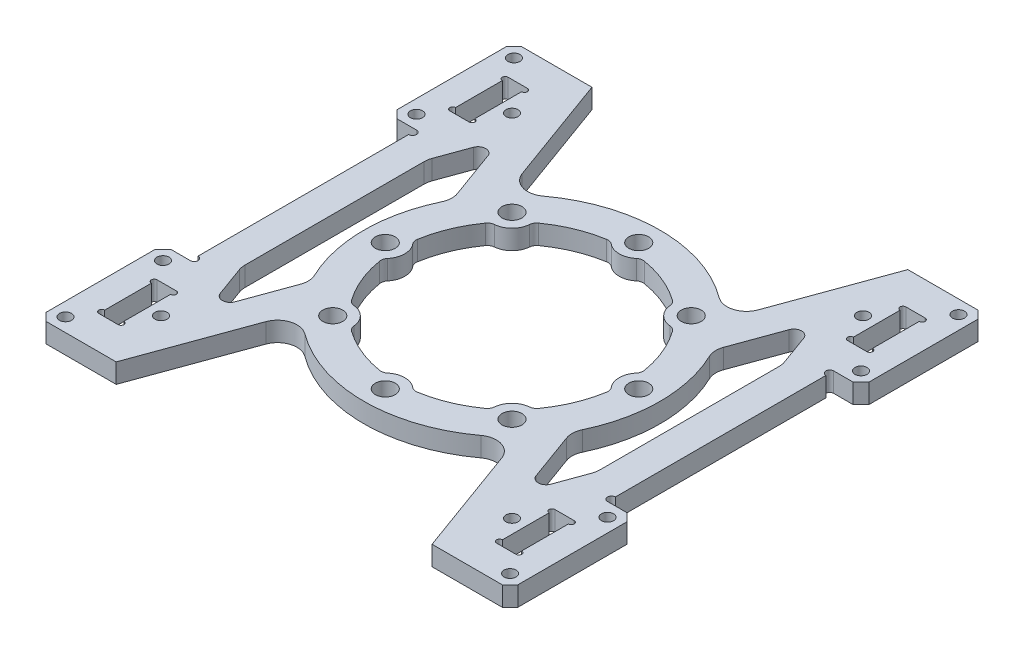
from build123d import *

# Parameters (mm, degrees)
SKETCH_1_W          = 121
SKETCH_1_H          = 122
SKETCH_1_R          = 2.55
SKETCH_1_R_2        = 1.55
SKETCH_1_W_2        = 4.95
SKETCH_1_H_2        = 14.95
EXTRUDE_1_DEPTH     = 2.5
FILLET_1_R          = 2
SKETCH_2_R          = 0.75
CUT_EXTRUDE_1_DEPTH = 6.0000001
SKETCH_3_W          = 7
SKETCH_3_H          = 58
CUT_EXTRUDE_2_DEPTH = 6.0000001
CUT_EXTRUDE_3_DEPTH = 6.0000001
FILLET_2_R          = 5
CUT_EXTRUDE_4_DEPTH = 6.0000001
FILLET_3_R          = 2
CHAMFER_1_SIZE      = 2
FILLET_4_R          = 5
SKETCH_6_R          = 1
CUT_EXTRUDE_5_DEPTH = 6.0000001


with BuildPart() as part:
    # 草图1 → 凸台-拉伸1 (new body, symmetric)
    with BuildSketch(Plane(origin=(0, 0, 0), x_dir=(1, 0, 0), z_dir=(0, 1, 0))):
        Rectangle(SKETCH_1_W, SKETCH_1_H)
        with Locations((0, 32.5)):
            Circle(SKETCH_1_R, mode=Mode.SUBTRACT)
        with Locations((22.980970389, 22.980970389)):
            Circle(SKETCH_1_R, mode=Mode.SUBTRACT)
        with Locations((32.5, 0)):
            Circle(SKETCH_1_R, mode=Mode.SUBTRACT)
        with Locations((22.980970389, -22.980970389)):
            Circle(SKETCH_1_R, mode=Mode.SUBTRACT)
        with Locations((0, -32.5)):
            Circle(SKETCH_1_R, mode=Mode.SUBTRACT)
        with Locations((-22.980970389, -22.980970389)):
            Circle(SKETCH_1_R, mode=Mode.SUBTRACT)
        with Locations((-32.5, 0)):
            Circle(SKETCH_1_R, mode=Mode.SUBTRACT)
        with Locations((-22.980970389, 22.980970389)):
            Circle(SKETCH_1_R, mode=Mode.SUBTRACT)
        with Locations((-57, 57.5)):
            Circle(SKETCH_1_R_2, mode=Mode.SUBTRACT)
        with Locations((-57, 32.5)):
            Circle(SKETCH_1_R_2, mode=Mode.SUBTRACT)
        with Locations((57, 32.5)):
            Circle(SKETCH_1_R_2, mode=Mode.SUBTRACT)
        with Locations((57, 57.5)):
            Circle(SKETCH_1_R_2, mode=Mode.SUBTRACT)
        with Locations((57, -32.5)):
            Circle(SKETCH_1_R_2, mode=Mode.SUBTRACT)
        with Locations((57, -57.5)):
            Circle(SKETCH_1_R_2, mode=Mode.SUBTRACT)
        with Locations((-57, -32.5)):
            Circle(SKETCH_1_R_2, mode=Mode.SUBTRACT)
        with Locations((-57, -57.5)):
            Circle(SKETCH_1_R_2, mode=Mode.SUBTRACT)
        with Locations((-45, 45)):
            Circle(SKETCH_1_R_2, mode=Mode.SUBTRACT)
        with Locations((45, 45)):
            Circle(SKETCH_1_R_2, mode=Mode.SUBTRACT)
        with Locations((45, -45)):
            Circle(SKETCH_1_R_2, mode=Mode.SUBTRACT)
        with Locations((-45, -45)):
            Circle(SKETCH_1_R_2, mode=Mode.SUBTRACT)
        with Locations((-51, 45)):
            Rectangle(SKETCH_1_W_2, SKETCH_1_H_2, mode=Mode.SUBTRACT)
        with Locations((-51, -45)):
            Rectangle(SKETCH_1_W_2, SKETCH_1_H_2, mode=Mode.SUBTRACT)
        with Locations((51, -45)):
            Rectangle(SKETCH_1_W_2, SKETCH_1_H_2, mode=Mode.SUBTRACT)
        with Locations((51, 45)):
            Rectangle(SKETCH_1_W_2, SKETCH_1_H_2, mode=Mode.SUBTRACT)
        with BuildLine():
            ThreePointArc((-23.374689978, 17.996496005), (-27.254446209, 11.289161255), (-29.253846154, 3.802957429))
            ThreePointArc((-29.253846154, 3.802957429), (-27.5, 0), (-29.253846154, -3.802957429))
            ThreePointArc((-29.253846154, -3.802957429), (-27.254446209, -11.289161255), (-23.374689978, -17.996496005))
            ThreePointArc((-23.374689978, -17.996496005), (-19.445436483, -19.445436483), (-17.996496005, -23.374689978))
            ThreePointArc((-17.996496005, -23.374689978), (-11.289161255, -27.254446209), (-3.802957429, -29.253846154))
            ThreePointArc((-3.802957429, -29.253846154), (0, -27.5), (3.802957429, -29.253846154))
            ThreePointArc((3.802957429, -29.253846154), (11.289161255, -27.254446209), (17.996496005, -23.374689978))
            ThreePointArc((17.996496005, -23.374689978), (19.445436483, -19.445436483), (23.374689978, -17.996496005))
            ThreePointArc((23.374689978, -17.996496005), (27.254446209, -11.289161255), (29.253846154, -3.802957429))
            ThreePointArc((29.253846154, -3.802957429), (27.5, 0), (29.253846154, 3.802957429))
            ThreePointArc((29.253846154, 3.802957429), (27.254446209, 11.289161255), (23.374689978, 17.996496005))
            ThreePointArc((23.374689978, 17.996496005), (19.445436483, 19.445436483), (17.996496005, 23.374689978))
            ThreePointArc((17.996496005, 23.374689978), (11.289161255, 27.254446209), (3.802957429, 29.253846154))
            ThreePointArc((3.802957429, 29.253846154), (0, 27.5), (-3.802957429, 29.253846154))
            ThreePointArc((-3.802957429, 29.253846154), (-11.289161255, 27.254446209), (-17.996496005, 23.374689978))
            ThreePointArc((-17.996496005, 23.374689978), (-19.445436483, 19.445436483), (-23.374689978, 17.996496005))
        make_face(mode=Mode.SUBTRACT)
    extrude(amount=EXTRUDE_1_DEPTH, both=True)

    # 圆角1
    fillet_1_edges = [part.edges().sort_by_distance(p)[0] for p in [
        (-17.996496005, 0, -23.374689978),
        (-23.374689978, 0, -17.996496005),
        (-29.253846154, 0, -3.802957429),
        (-29.253846154, 0, 3.802957429),
        (-23.374689978, 0, 17.996496005),
        (-17.996496005, 0, 23.374689978),
        (-3.802957429, 0, 29.253846154),
        (3.802957429, 0, 29.253846154),
        (17.996496005, 0, 23.374689978),
        (23.374689978, 0, 17.996496005),
        (29.253846154, 0, 3.802957429),
        (29.253846154, 0, -3.802957429),
        (23.374689978, 0, -17.996496005),
        (17.996496005, 0, -23.374689978),
        (3.802957429, 0, -29.253846154),
        (-3.802957429, 0, -29.253846154),
    ]]
    fillet(fillet_1_edges, radius=FILLET_1_R)

    # 草图2 → 切除-拉伸1 (cut, through all)
    with BuildSketch(Plane(origin=(0, 2.5, 0), x_dir=(1, 0, 0), z_dir=(0, 1, 0))):
        with Locations((-53.475, 51.725)):
            Circle(SKETCH_2_R)
        with Locations((-53.475, 38.275)):
            Circle(SKETCH_2_R)
        with Locations((-48.525, 38.275)):
            Circle(SKETCH_2_R)
        with Locations((-48.525, 51.725)):
            Circle(SKETCH_2_R)
        with Locations((-53.475, -38.275)):
            Circle(SKETCH_2_R)
        with Locations((-48.525, -38.275)):
            Circle(SKETCH_2_R)
        with Locations((-53.475, -51.725)):
            Circle(SKETCH_2_R)
        with Locations((-48.525, -51.725)):
            Circle(SKETCH_2_R)
        with Locations((48.525, -51.725)):
            Circle(SKETCH_2_R)
        with Locations((53.475, -51.725)):
            Circle(SKETCH_2_R)
        with Locations((48.525, -38.275)):
            Circle(SKETCH_2_R)
        with Locations((53.475, -38.275)):
            Circle(SKETCH_2_R)
        with Locations((48.525, 51.725)):
            Circle(SKETCH_2_R)
        with Locations((53.475, 51.725)):
            Circle(SKETCH_2_R)
        with Locations((48.525, 38.275)):
            Circle(SKETCH_2_R)
        with Locations((53.475, 38.275)):
            Circle(SKETCH_2_R)
    extrude(amount=-CUT_EXTRUDE_1_DEPTH, mode=Mode.SUBTRACT)

    # 草图3 → 切除-拉伸2 (cut, through all)
    with BuildSketch(Plane(origin=(0, 2.5, 0), x_dir=(1, 0, 0), z_dir=(0, 1, 0))):
        with Locations((-57, 0)):
            Rectangle(SKETCH_3_W, SKETCH_3_H)
        with Locations((57, 0)):
            Rectangle(SKETCH_3_W, SKETCH_3_H)
    extrude(amount=-CUT_EXTRUDE_2_DEPTH, mode=Mode.SUBTRACT)

    # 草图4 → 切除-拉伸3 (cut, through all)
    with BuildSketch(Plane(origin=(0, 2.5, 0), x_dir=(1, 0, 0), z_dir=(0, 1, 0))):
        with BuildLine():
            Line((-40.5, 61), (-27.747548247, 25.962926766))
            ThreePointArc((-27.747548247, 25.962926766), (0, 38), (27.747548247, 25.962926766))
            Line((27.747548247, 25.962926766), (40.5, 61))
            Line((40.5, 61), (-40.5, 61))
        make_face()
        with BuildLine():
            Line((40.5, -61), (27.747548247, -25.962926766))
            ThreePointArc((27.747548247, -25.962926766), (0, -38), (-27.747548247, -25.962926766))
            Line((-27.747548247, -25.962926766), (-40.5, -61))
            Line((-40.5, -61), (40.5, -61))
        make_face()
    extrude(amount=-CUT_EXTRUDE_3_DEPTH, mode=Mode.SUBTRACT)

    # 圆角2
    fillet_2_edges = [part.edges().sort_by_distance(p)[0] for p in [
        (-27.747548247, 0, 25.962926766),
        (27.747548247, 0, 25.962926766),
        (27.747548247, 0, -25.962926766),
        (-27.747548247, 0, -25.962926766),
    ]]
    fillet(fillet_2_edges, radius=FILLET_2_R)

    # 草图5 → 切除-拉伸4 (cut, through all)
    with BuildSketch(Plane(origin=(0, 2.5, 0), x_dir=(1, 0, 0), z_dir=(0, 1, 0))):
        with BuildLine():
            Line((-40.5, 37.609564799), (-33.404451885, 18.114706574))
            ThreePointArc((-33.404451885, 18.114706574), (-38, 0), (-33.404451885, -18.114706574))
            Line((-33.404451885, -18.114706574), (-40.5, -37.609564799))
            Line((-40.5, -37.609564799), (-45.5, -23.872177701))
            Line((-45.5, -23.872177701), (-45.5, 23.872177701))
            Line((-45.5, 23.872177701), (-40.5, 37.609564799))
        make_face()
        with BuildLine():
            Line((40.5, 37.609564799), (33.404451885, 18.114706574))
            ThreePointArc((33.404451885, 18.114706574), (38, 0), (33.404451885, -18.114706574))
            Line((33.404451885, -18.114706574), (40.5, -37.609564799))
            Line((40.5, -37.609564799), (45.5, -23.872177701))
            Line((45.5, -23.872177701), (45.5, 23.872177701))
            Line((45.5, 23.872177701), (40.5, 37.609564799))
        make_face()
    extrude(amount=-CUT_EXTRUDE_4_DEPTH, mode=Mode.SUBTRACT)

    # 圆角3
    fillet_3_edges = [part.edges().sort_by_distance(p)[0] for p in [
        (-40.5, 0, -37.609564799),
        (-40.5, 0, 37.609564799),
        (40.5, 0, -37.609564799),
        (40.5, 0, 37.609564799),
    ]]
    fillet(fillet_3_edges, radius=FILLET_3_R)

    # 倒角1
    chamfer_1_edges = [part.edges().sort_by_distance(p)[0] for p in [
        (-60.5, 0, 29),
        (-60.5, 0, -29),
        (60.5, 0, -29),
        (60.5, 0, 29),
        (-60.5, 0, -61),
        (60.5, 0, -61),
        (60.5, 0, 61),
        (-60.5, 0, 61),
    ]]
    chamfer(chamfer_1_edges, length=CHAMFER_1_SIZE)

    # 圆角4
    fillet_4_edges = [part.edges().sort_by_distance(p)[0] for p in [
        (-45.5, 0, -23.872177701),
        (-33.404451885, 0, -18.114706574),
        (-33.404451885, 0, 18.114706574),
        (-45.5, 0, 23.872177701),
        (45.5, 0, -23.872177701),
        (45.5, 0, 23.872177701),
        (33.404451885, 0, 18.114706574),
        (33.404451885, 0, -18.114706574),
    ]]
    fillet(fillet_4_edges, radius=FILLET_4_R)

    # 草图6 → 切除-拉伸5 (cut, through all)
    with BuildSketch(Plane(origin=(0, 2.5, 0), x_dir=(1, 0, 0), z_dir=(0, 1, 0))):
        with Locations((-53.5, 28)):
            Circle(SKETCH_6_R)
        with Locations((-53.5, -28)):
            Circle(SKETCH_6_R)
        with Locations((53.5, -28)):
            Circle(SKETCH_6_R)
        with Locations((53.5, 28)):
            Circle(SKETCH_6_R)
    extrude(amount=-CUT_EXTRUDE_5_DEPTH, mode=Mode.SUBTRACT)


solid = part.part
